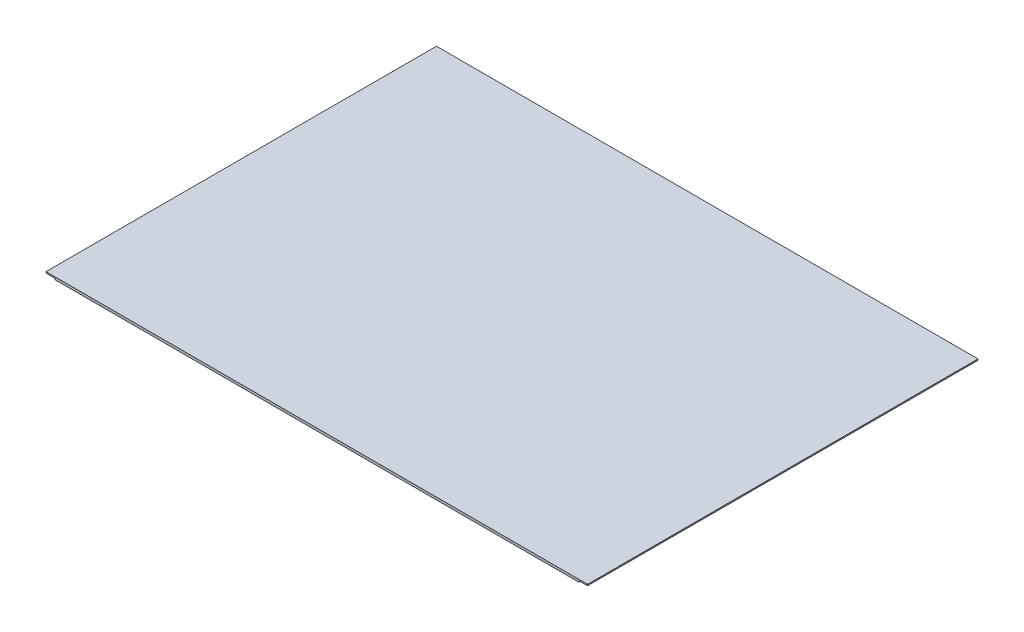
from build123d import *

# Parameters (mm, degrees)
SKETCH1_W           = 430
SKETCH1_H           = 310
BOSS_EXTRUDE1_DEPTH = 2
SKETCH2_W           = 7
SKETCH2_H           = 1
CUT_EXTRUDE1_DEPTH  = 311


with BuildPart() as part:
    # Sketch1 → Boss-Extrude1 (new body)
    with BuildSketch(Plane(origin=(0, 0, 0), x_dir=(1, 0, 0), z_dir=(0, 1, 0))):
        Rectangle(SKETCH1_W, SKETCH1_H)
    extrude(amount=BOSS_EXTRUDE1_DEPTH)

    # Sketch2 → Cut-Extrude1 (cut, through all)
    with BuildSketch(Plane.XY.offset(155)):
        with Locations((-211.5, 0.5)):
            Rectangle(SKETCH2_W, SKETCH2_H)
        with Locations((211.5, 0.5)):
            Rectangle(SKETCH2_W, SKETCH2_H)
    extrude(amount=-CUT_EXTRUDE1_DEPTH, mode=Mode.SUBTRACT)


solid = part.part
